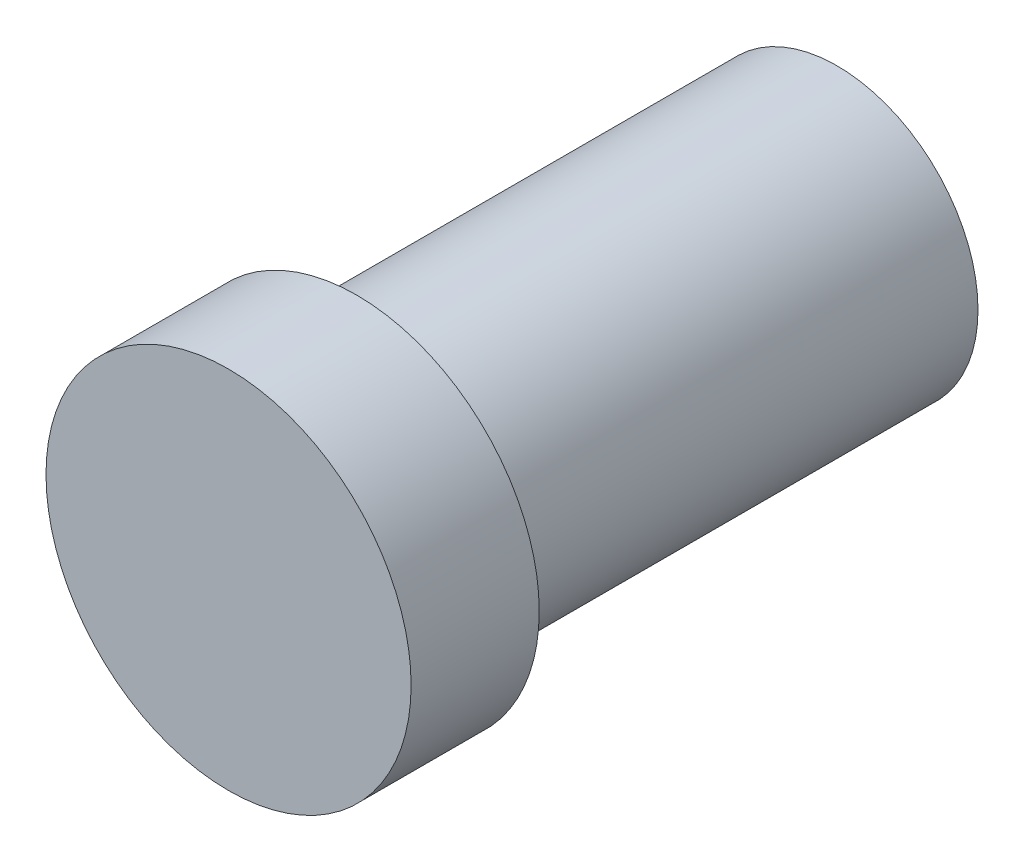
from build123d import *

# Parameters (mm, degrees)
SKETCH1_R           = 22
BOSS_EXTRUDE1_DEPTH = 75
SKETCH2_R           = 28.5
BOSS_EXTRUDE2_DEPTH = 20
FILLET1_R           = 2


with BuildPart() as part:
    # Sketch1 → Boss-Extrude1 (new body)
    with BuildSketch(Plane.XY):
        Circle(SKETCH1_R)
    extrude(amount=-BOSS_EXTRUDE1_DEPTH)

    # Sketch2 → Boss-Extrude2 (add)
    with BuildSketch(Plane.XY):
        Circle(SKETCH2_R)
    extrude(amount=BOSS_EXTRUDE2_DEPTH)

    # Fillet1
    fillet1_edges = [part.edges().sort_by_distance(p)[0] for p in [
        (-22, 0, 0),
    ]]
    fillet(fillet1_edges, radius=FILLET1_R)


solid = part.part
